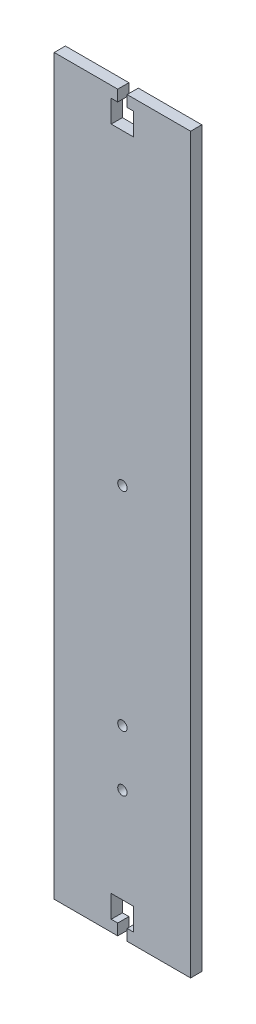
from build123d import *

# Parameters (mm, degrees)
SKETCH1_W           = 61.01
SKETCH1_H           = 328
BOSS_EXTRUDE1_DEPTH = 5
SKETCH2_R           = 2.1
CUT_EXTRUDE1_DEPTH  = 10
CUT_EXTRUDE2_DEPTH  = 10
SKETCH4_R           = 2.1
CUT_EXTRUDE3_DEPTH  = 5
SKETCH5_R           = 2.1
CUT_EXTRUDE4_DEPTH  = 5


with BuildPart() as part:
    # Sketch1 → Boss-Extrude1 (new body)
    with BuildSketch(Plane.XY):
        Rectangle(SKETCH1_W, SKETCH1_H)
    extrude(amount=BOSS_EXTRUDE1_DEPTH)

    # Sketch2 → Cut-Extrude1 (cut)
    with BuildSketch(Plane.XY.offset(5)):
        with Locations((0, -81.5)):
            Circle(SKETCH2_R)
    extrude(amount=-CUT_EXTRUDE1_DEPTH, mode=Mode.SUBTRACT)

    # Sketch3 → Cut-Extrude2 (cut)
    with BuildSketch(Plane.XY.offset(5)):
        Polygon((-2.1, -164), (-2.1, -159), (-5, -159), (-5, -149), (5, -149), (5, -159), (2.1, -159), (2.1, -164), align=None)
        Polygon((2.1, 164), (2.1, 159), (5, 159), (5, 149), (-5, 149), (-5, 159), (-2.1, 159), (-2.1, 164), align=None)
    extrude(amount=-CUT_EXTRUDE2_DEPTH, mode=Mode.SUBTRACT)

    # Sketch4 → Cut-Extrude3 (cut)
    with BuildSketch(Plane.XY.offset(5)):
        with Locations((0, -106.5)):
            Circle(SKETCH4_R)
    extrude(amount=-CUT_EXTRUDE3_DEPTH, mode=Mode.SUBTRACT)

    # Sketch5 → Cut-Extrude4 (cut)
    with BuildSketch(Plane.XY.offset(5)):
        with Locations((0, 11.5)):
            Circle(SKETCH5_R)
    extrude(amount=-CUT_EXTRUDE4_DEPTH, mode=Mode.SUBTRACT)


solid = part.part
